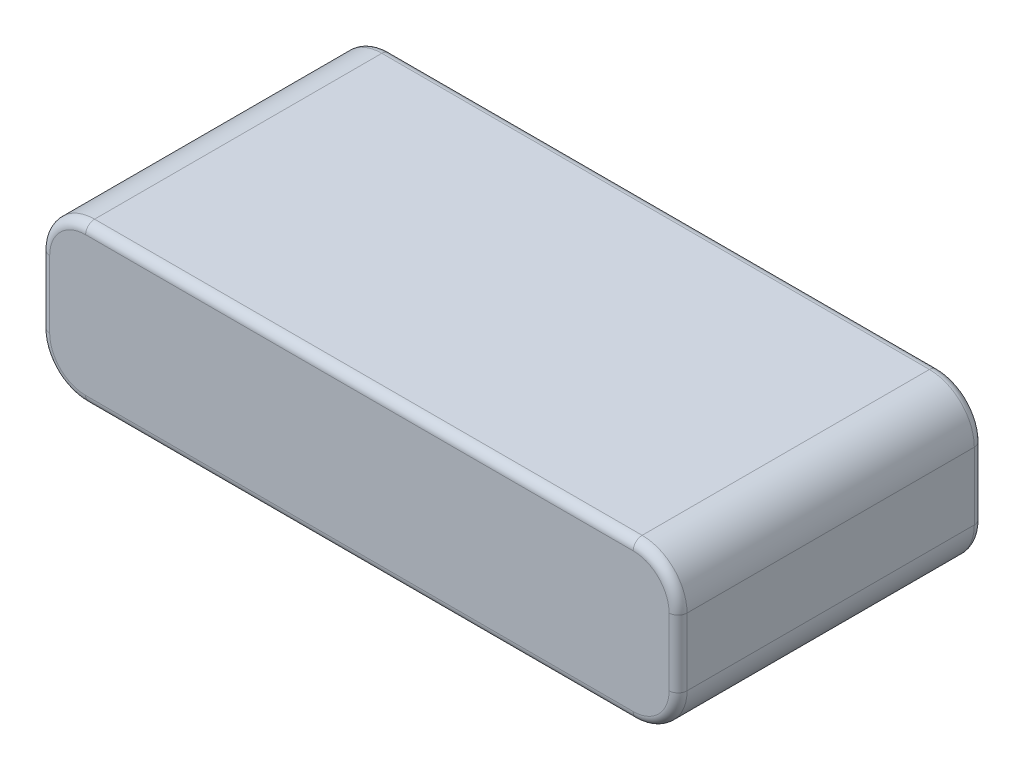
from build123d import *

# Parameters (mm, degrees)
SKETCH4_W           = 71
SKETCH4_H           = 34
BOSS_EXTRUDE1_DEPTH = 17.5
FILLET1_R           = 5
FILLET2_R           = 1


with BuildPart() as part:
    # Sketch4 → Boss-Extrude1 (new body)
    with BuildSketch(Plane(origin=(0, 0, 0), x_dir=(1, 0, 0), z_dir=(0, 1, 0))):
        Rectangle(SKETCH4_W, SKETCH4_H)
    extrude(amount=BOSS_EXTRUDE1_DEPTH)

    # Fillet1
    fillet1_edges = [part.edges().sort_by_distance(p)[0] for p in [
        (35.5, 17.5, 0),
        (-35.5, 17.5, 0),
        (35.5, 0, 0),
        (-35.5, 0, 0),
    ]]
    fillet(fillet1_edges, radius=FILLET1_R)

    # Fillet2
    fillet2_edges = [part.edges().sort_by_distance(p)[0] for p in [
        (0, 17.5, 17),
        (0, 17.5, -17),
        (0, 0, 17),
        (35.5, 8.75, 17),
        (-35.5, 8.75, 17),
        (34.035533906, 16.035533906, 17),
        (34.035533906, 1.464466094, 17),
        (-34.035533906, 1.464466094, 17),
        (-34.035533906, 16.035533906, 17),
        (-35.5, 8.75, -17),
        (0, 0, -17),
        (35.5, 8.75, -17),
        (34.035533906, 16.035533906, -17),
        (34.035533906, 1.464466094, -17),
        (-34.035533906, 1.464466094, -17),
        (-34.035533906, 16.035533906, -17),
    ]]
    fillet(fillet2_edges, radius=FILLET2_R)


solid = part.part
